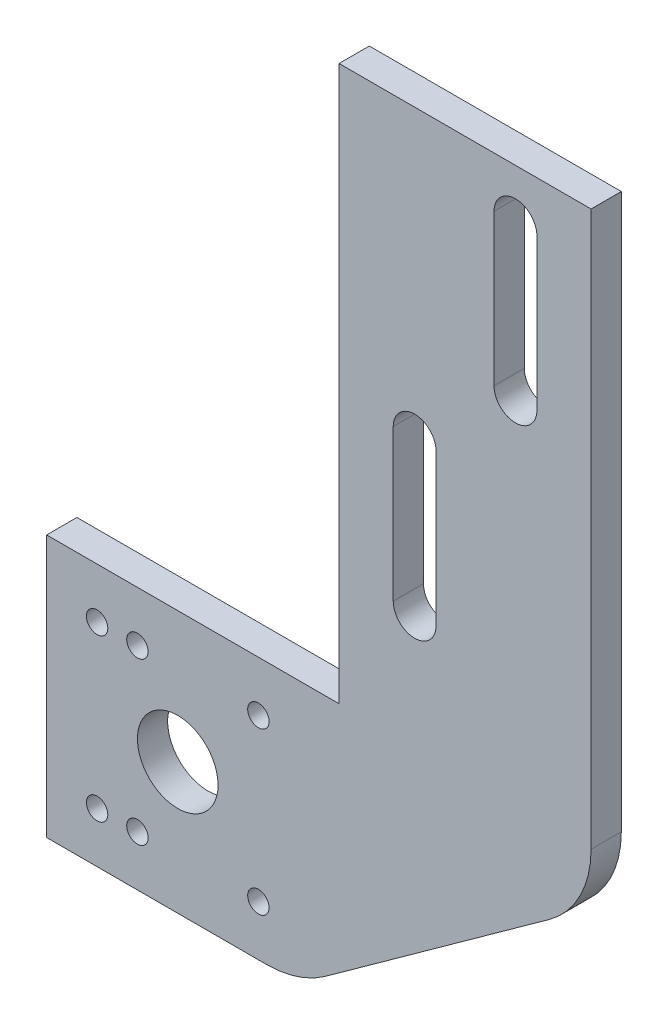
from build123d import *

# Parameters (mm, degrees)
SKETCH_1_R      = 2.125
SKETCH_1_R_2    = 8
EXTRUDE_1_DEPTH = 6


with BuildPart() as part:
    # 草图1 → 凸台-拉伸1 (new body)
    with BuildSketch(Plane.XY):
        with BuildLine():
            Line((-22.390026272, -12.434766873), (21.159720544, -12.434766873))
            ThreePointArc((21.159720544, -12.434766873), (27.298604017, -11.469317294), (32.844809242, -8.666177844))
            Line((32.844809242, -8.666177844), (77.295062426, 23.333822156))
            ThreePointArc((77.295062426, 23.333822156), (83.410279539, 30.44661958), (85.609973728, 39.565233127))
            Line((85.609973728, 39.565233127), (85.609973728, 149.565233127))
            Line((85.609973728, 149.565233127), (35.609973728, 149.565233127))
            Line((35.609973728, 149.565233127), (35.609973728, 39.565233127))
            Line((35.609973728, 39.565233127), (27.609973728, 39.565233127))
            Line((27.609973728, 39.565233127), (-22.390026272, 39.565233127))
            Line((-22.390026272, 39.565233127), (-22.390026272, -12.434766873))
        make_face()
        with Locations((-12.390026272, -2.434766873)):
            Circle(SKETCH_1_R, mode=Mode.SUBTRACT)
        with Locations((-4.390026272, -2.434766873)):
            Circle(SKETCH_1_R, mode=Mode.SUBTRACT)
        with Locations((19.609973728, -2.434766873)):
            Circle(SKETCH_1_R, mode=Mode.SUBTRACT)
        with Locations((-12.390026272, 29.565233127)):
            Circle(SKETCH_1_R, mode=Mode.SUBTRACT)
        with Locations((-4.390026272, 29.565233127)):
            Circle(SKETCH_1_R, mode=Mode.SUBTRACT)
        with Locations((19.609973728, 29.565233127)):
            Circle(SKETCH_1_R, mode=Mode.SUBTRACT)
        with Locations((3.609973728, 13.565233127)):
            Circle(SKETCH_1_R_2, mode=Mode.SUBTRACT)
        with BuildLine():
            Line((54.859973728, 92.565233127), (54.859973728, 62.565233127))
            ThreePointArc((54.859973728, 62.565233127), (50.609973728, 58.315233127), (46.359973728, 62.565233127))
            Line((46.359973728, 62.565233127), (46.359973728, 92.565233127))
            ThreePointArc((46.359973728, 92.565233127), (50.609973728, 96.815233127), (54.859973728, 92.565233127))
        make_face(mode=Mode.SUBTRACT)
        with BuildLine():
            Line((66.359973728, 109.565233127), (66.359973728, 139.565233127))
            ThreePointArc((66.359973728, 139.565233127), (70.609973728, 143.815233127), (74.859973728, 139.565233127))
            Line((74.859973728, 139.565233127), (74.859973728, 109.565233127))
            ThreePointArc((74.859973728, 109.565233127), (70.609973728, 105.315233127), (66.359973728, 109.565233127))
        make_face(mode=Mode.SUBTRACT)
    extrude(amount=EXTRUDE_1_DEPTH)


solid = part.part
